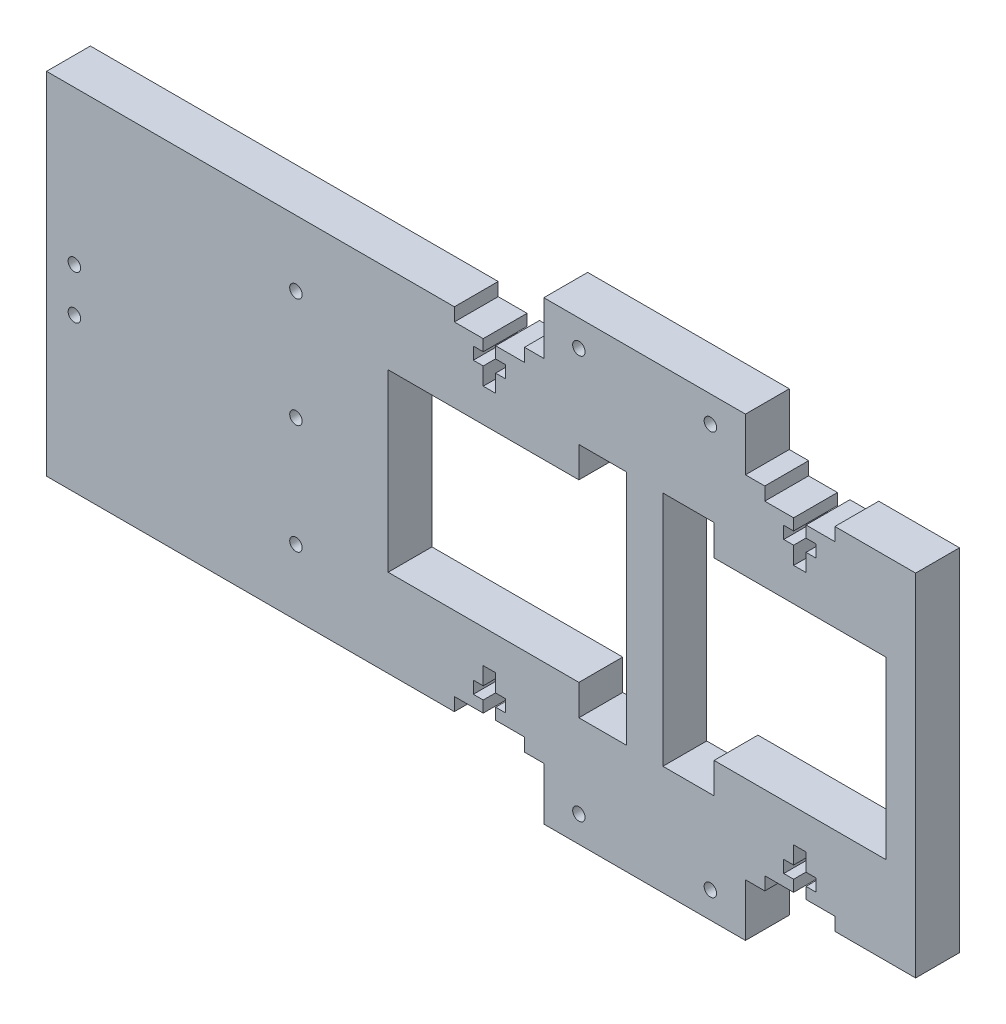
from build123d import *

# Parameters (mm, degrees)
SKETCH1_R           = 1.42
BOSS_EXTRUDE1_DEPTH = 10


with BuildPart() as part:
    # Sketch1 → Boss-Extrude1 (new body)
    with BuildSketch(Plane.XY):
        Polygon((109, 80), (109, 77), (115.58, 77), (115.58, 74.4), (113.33, 74.4), (113.33, 71.6), (115.58, 71.6), (115.58, 67.6), (118.42, 67.6), (118.42, 71.6), (120.67, 71.6), (120.67, 74.4), (118.42, 74.4), (118.42, 77), (125, 77), (125, 80), (143.417515172, 80), (143.417515172, 60), (143.417515172, 20), (143.417515172, 0), (125, 0), (125, 3), (118.42, 3), (118.42, 5.6), (120.67, 5.6), (120.67, 8.4), (118.42, 8.4), (118.42, 12.4), (115.58, 12.4), (115.58, 8.4), (113.33, 8.4), (113.33, 5.6), (115.58, 5.6), (115.58, 3), (109, 3), (109, 0), (104.593570259, 0), (104.593570259, -12), (58.593570259, -12), (58.593570259, 0), (54.187140517, 0), (54.187140517, 3), (47.607140517, 3), (47.607140517, 5.6), (49.857140517, 5.6), (49.857140517, 8.4), (47.607140517, 8.4), (47.607140517, 12.4), (44.767140517, 12.4), (44.767140517, 8.4), (42.517140517, 8.4), (42.517140517, 5.6), (44.767140517, 5.6), (44.767140517, 3), (38.187140517, 3), (38.187140517, 0), (0, 0), (-15.602079829, 0), (-54.853791786, 0), (-54.853791786, 80), (-15.602079829, 80), (5, 80), (38.187140517, 80), (38.187140517, 77), (44.767140517, 77), (44.767140517, 74.4), (42.517140517, 74.4), (42.517140517, 71.6), (44.767140517, 71.6), (44.767140517, 67.6), (47.607140517, 67.6), (47.607140517, 71.6), (49.857140517, 71.6), (49.857140517, 74.4), (47.607140517, 74.4), (47.607140517, 77), (54.187140517, 77), (54.187140517, 80), (58.593570259, 80), (58.593570259, 92), (104.593570259, 92), (104.593570259, 80), align=None)
        with Locations((2.037759908, 40)):
            Circle(SKETCH1_R, mode=Mode.SUBTRACT)
        with Locations((2.037759908, 65)):
            Circle(SKETCH1_R, mode=Mode.SUBTRACT)
        with Locations((2.037759908, 15)):
            Circle(SKETCH1_R, mode=Mode.SUBTRACT)
        with Locations((66.593570259, 86)):
            Circle(SKETCH1_R, mode=Mode.SUBTRACT)
        with Locations((96.593570259, 86)):
            Circle(SKETCH1_R, mode=Mode.SUBTRACT)
        with Locations((96.593570259, -6)):
            Circle(SKETCH1_R, mode=Mode.SUBTRACT)
        with Locations((66.593570259, -6)):
            Circle(SKETCH1_R, mode=Mode.SUBTRACT)
        with Locations((-48.502415741, 45)):
            Circle(SKETCH1_R, mode=Mode.SUBTRACT)
        with Locations((-48.502415741, 35)):
            Circle(SKETCH1_R, mode=Mode.SUBTRACT)
        Polygon((136.600558962, 60), (136.600558962, 20), (97.442765105, 20), (97.442765105, 13), (85.759642836, 13), (85.759642836, 67), (97.442765105, 67), (97.442765105, 60), align=None, mode=Mode.SUBTRACT)
        Polygon((23.079003763, 60), (66.593570259, 60), (66.593570259, 67), (77.427497681, 67), (77.427497681, 13), (66.593570259, 13), (66.593570259, 20), (23.079003763, 20), align=None, mode=Mode.SUBTRACT)
    extrude(amount=BOSS_EXTRUDE1_DEPTH)


solid = part.part
